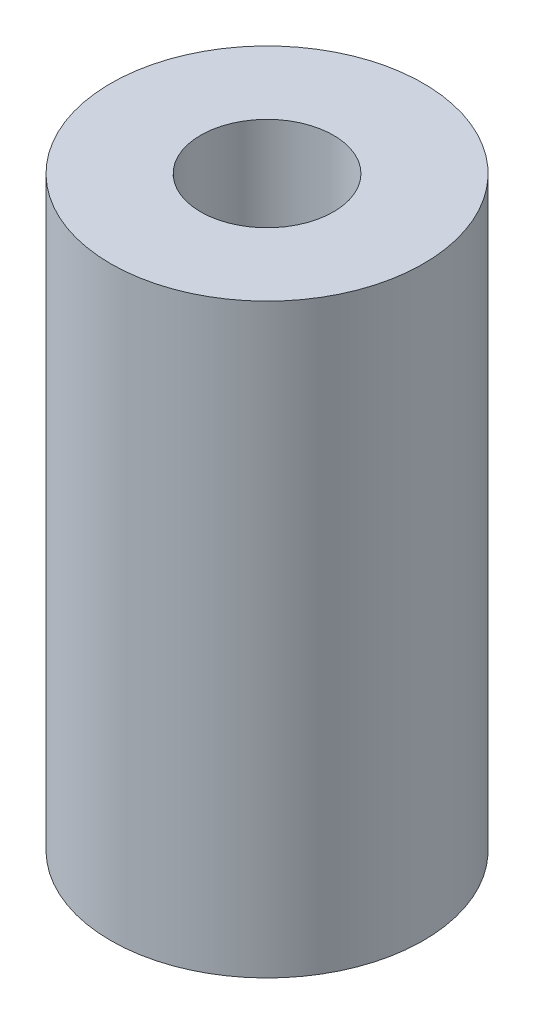
from build123d import *

# Parameters (mm, degrees)
SKETCH1_R           = 4
SKETCH1_R_2         = 1.7
BOSS_EXTRUDE1_DEPTH = 15


with BuildPart() as part:
    # Sketch1 → Boss-Extrude1 (new body)
    with BuildSketch(Plane(origin=(0, 0, 0), x_dir=(1, 0, 0), z_dir=(0, 1, 0))):
        Circle(SKETCH1_R)
        Circle(SKETCH1_R_2, mode=Mode.SUBTRACT)
    extrude(amount=BOSS_EXTRUDE1_DEPTH)


solid = part.part
